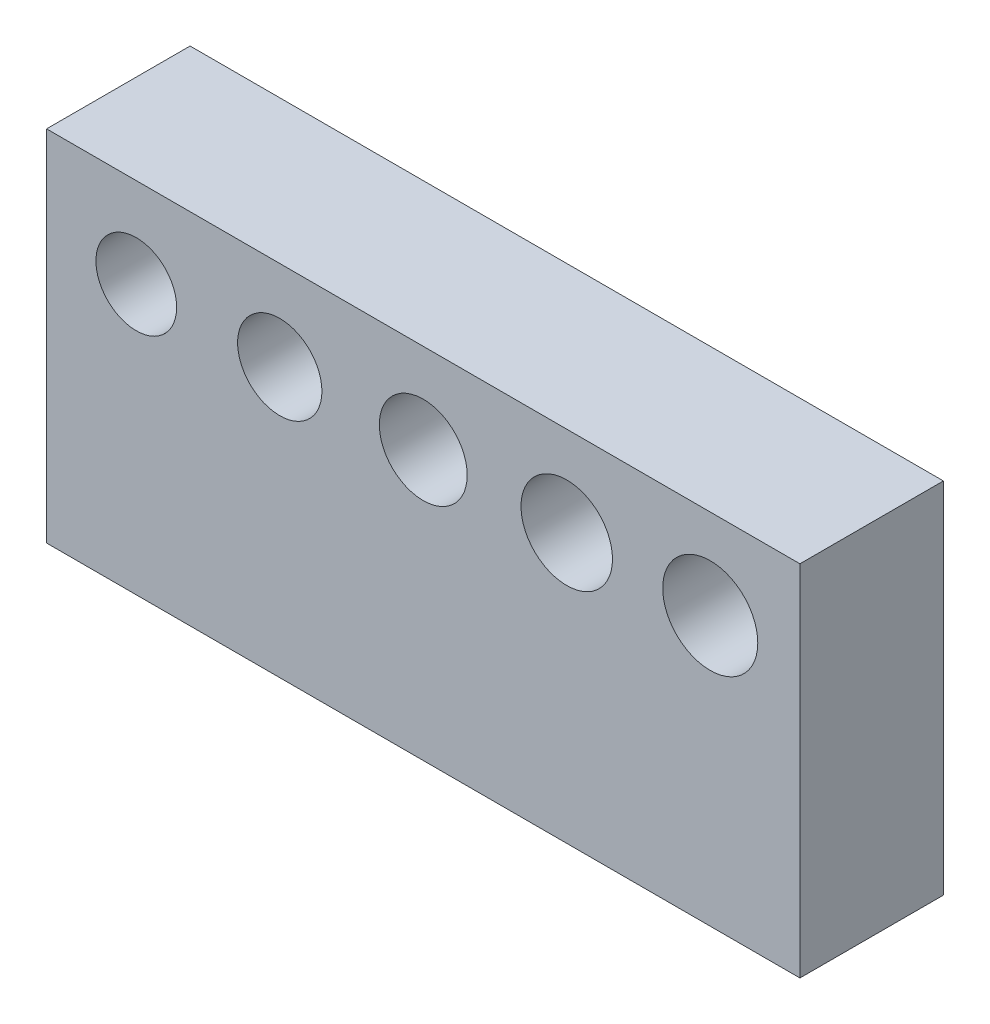
from build123d import *

# Parameters (mm, degrees)
SKETCH_1_W          = 42
SKETCH_1_H          = 20
EXTRUDE_1_DEPTH     = 8
SKETCH_2_R          = 2.25
SKETCH_2_R_2        = 2.35
SKETCH_2_R_3        = 2.45
SKETCH_2_R_4        = 2.55
SKETCH_2_R_5        = 2.65
CUT_EXTRUDE_1_DEPTH = 9
SKETCH_3_R          = 2.15
SKETCH_3_R_2        = 2.25
SKETCH_3_R_3        = 2.35
SKETCH_3_R_4        = 2.45
CUT_EXTRUDE_2_DEPTH = 10


with BuildPart() as part:
    # ｽｹｯﾁ1 → ﾎﾞｽ - 押し出し1 (new body)
    with BuildSketch(Plane.XY):
        Rectangle(SKETCH_1_W, SKETCH_1_H)
    extrude(amount=EXTRUDE_1_DEPTH)

    # ｽｹｯﾁ2 → ｶｯﾄ - 押し出し1 (cut, through all)
    with BuildSketch(Plane.XY.offset(8)):
        with Locations((-16, 5)):
            Circle(SKETCH_2_R)
        with Locations((-8, 5)):
            Circle(SKETCH_2_R_2)
        with Locations((0, 5)):
            Circle(SKETCH_2_R_3)
        with Locations((8, 5)):
            Circle(SKETCH_2_R_4)
        with Locations((16, 5)):
            Circle(SKETCH_2_R_5)
    extrude(amount=-CUT_EXTRUDE_1_DEPTH, mode=Mode.SUBTRACT)

    # ｽｹｯﾁ3 → ｶｯﾄ - 押し出し2 (cut)
    with BuildSketch(Plane.XZ.offset(10)):
        with Locations((-16, 4)):
            Circle(SKETCH_3_R)
        with Locations((-8, 4)):
            Circle(SKETCH_3_R_2)
        with Locations((0, 4)):
            Circle(SKETCH_3_R_3)
        with Locations((8, 4)):
            Circle(SKETCH_3_R_4)
    extrude(amount=-CUT_EXTRUDE_2_DEPTH, mode=Mode.SUBTRACT)


solid = part.part
